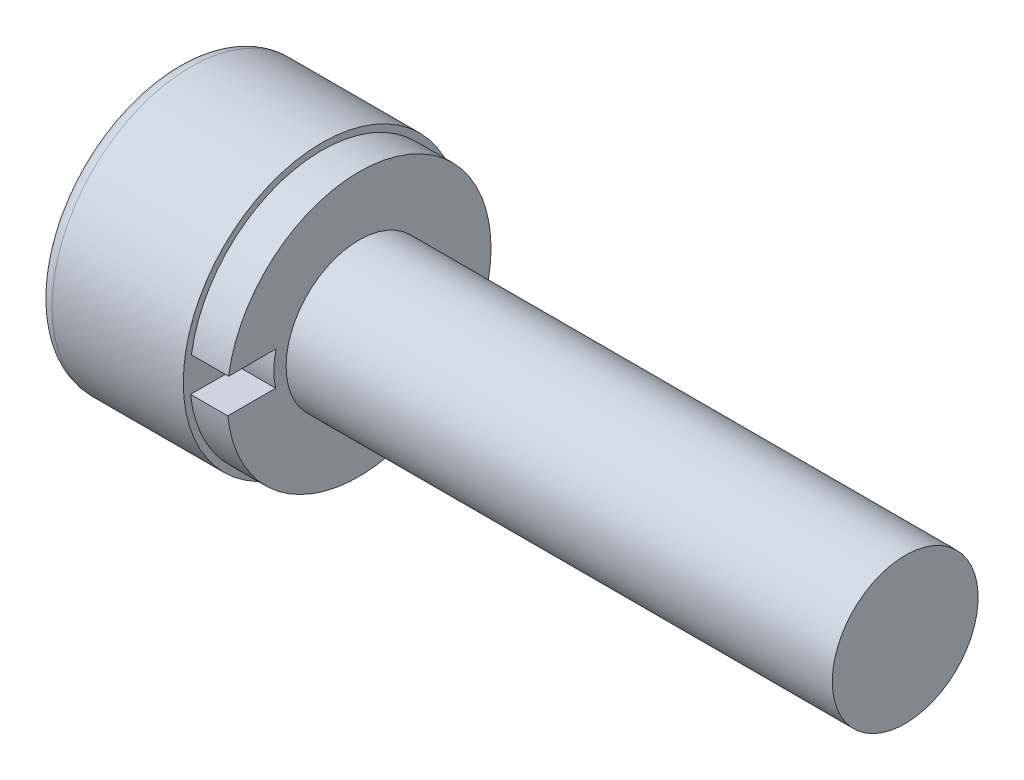
from build123d import *

# Parameters (mm, degrees)
CUT_EXTRUDE_1_DEPTH = 1
FILLET_1_R          = 0.2
CUT_EXTRUDE_2_DEPTH = 0.51


with BuildPart() as part:
    # 草图1 → 旋转1 (revolve)
    with BuildSketch(Plane.XY):
        Polygon((0, 0), (0, 1.9), (2, 1.9), (2, 1.81), (2.51, 1.81), (2.51, 1), (10, 1), (10, 0), align=None)
    revolve(axis=Axis((0, 0, 0), (1, 0, 0)))

    # 草图2 → 切除-拉伸1 (cut)
    with BuildSketch(Plane.ZY):
        Polygon((0.510545523, -0.727926234), (0.885675372, 0.078182276), (0.375129849, 0.80610851), (-0.510545523, 0.727926234), (-0.885675372, -0.078182276), (-0.375129849, -0.80610851), align=None)
    extrude(amount=-CUT_EXTRUDE_1_DEPTH, mode=Mode.SUBTRACT)

    # 圆角1
    fillet_1_edges = [part.edges().sort_by_distance(p)[0] for p in [
        (0, -1.9, 0),
    ]]
    fillet(fillet_1_edges, radius=FILLET_1_R)

    # 草图3 → 切除-拉伸2 (cut)
    with BuildSketch(Plane(origin=(2.51, 0, 0), x_dir=(0, 0, -1), z_dir=(1, 0, 0))):
        with BuildLine():
            Line((-1.138940095, 0.275804569), (-1.788863281, 0.275804569))
            ThreePointArc((-1.788863281, 0.275804569), (-1.809465078, 0.044001494), (-1.800154668, -0.188528969))
            Line((-1.800154668, -0.188528969), (-1.143106206, -0.188528969))
            ThreePointArc((-1.143106206, -0.188528969), (-1.168348286, 0.043882968), (-1.138940095, 0.275804569))
        make_face()
    extrude(amount=-CUT_EXTRUDE_2_DEPTH, mode=Mode.SUBTRACT)


solid = part.part
